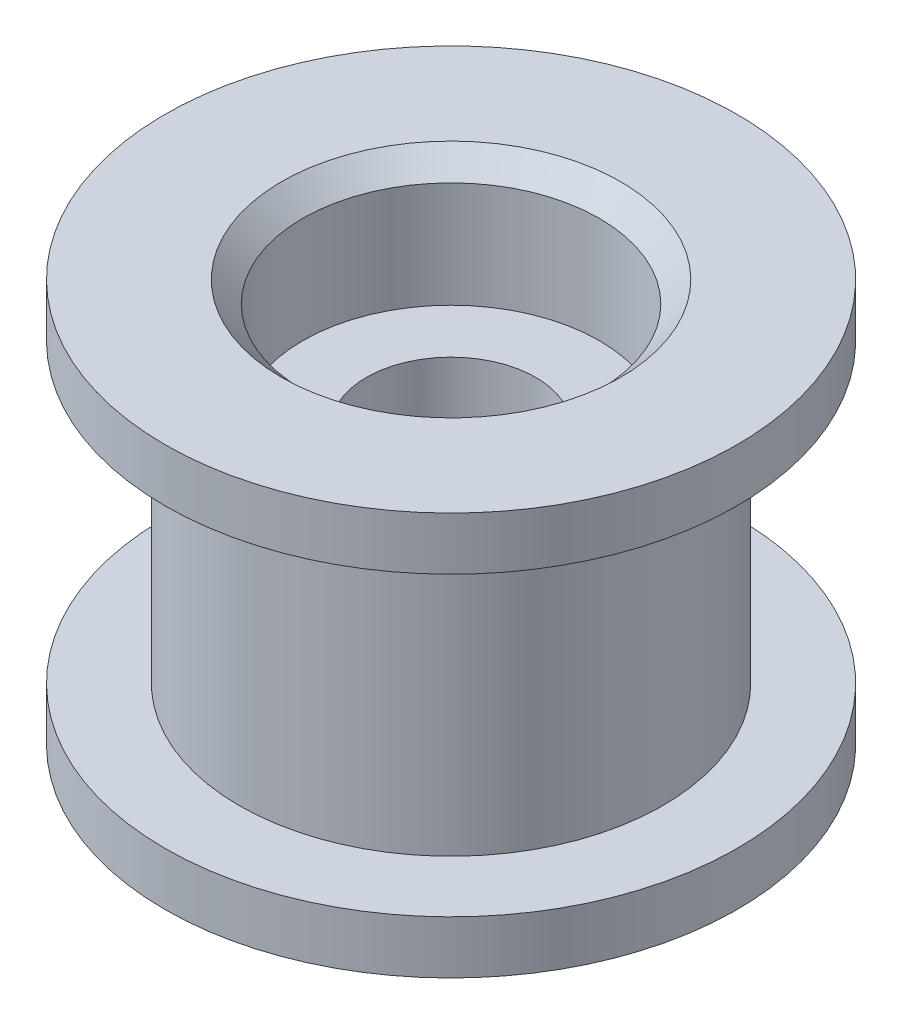
from build123d import *

# Parameters (mm, degrees)
SKETCH2_R           = 5
BOSS_EXTRUDE1_DEPTH = 7
SKETCH3_R           = 6.75
BOSS_EXTRUDE2_DEPTH = 1.25
BOSS_EXTRUDE3_START = -7
SKETCH3_2_R         = 6.75
BOSS_EXTRUDE3_DEPTH = 1.25
SKETCH4_R           = 3.5
CUT_EXTRUDE1_DEPTH  = 3
SKETCH5_R           = 3.5
CUT_EXTRUDE2_DEPTH  = 3
SKETCH6_R           = 2
CUT_EXTRUDE3_DEPTH  = 7.5
CHAMFER1_SIZE       = 0.5


with BuildPart() as part:
    # Sketch2 → Boss-Extrude1 (new body)
    with BuildSketch(Plane(origin=(0, 0, 0), x_dir=(1, 0, 0), z_dir=(0, 1, 0))):
        Circle(SKETCH2_R)
    extrude(amount=BOSS_EXTRUDE1_DEPTH)

    # Sketch3 → Boss-Extrude2 (add)
    with BuildSketch(Plane(origin=(0, 7, 0), x_dir=(1, 0, 0), z_dir=(0, 1, 0))):
        Circle(SKETCH3_R)
    extrude(amount=BOSS_EXTRUDE2_DEPTH)

    # Sketch3_2 → Boss-Extrude3 (add)
    with BuildSketch(Plane(origin=(0, 7, 0), x_dir=(1, 0, 0), z_dir=(0, 1, 0)).offset(BOSS_EXTRUDE3_START)):
        Circle(SKETCH3_2_R)
    extrude(amount=-BOSS_EXTRUDE3_DEPTH)

    # Sketch4 → Cut-Extrude1 (cut)
    with BuildSketch(Plane.XZ.offset(1.25)):
        Circle(SKETCH4_R)
    extrude(amount=-CUT_EXTRUDE1_DEPTH, mode=Mode.SUBTRACT)

    # Sketch5 → Cut-Extrude2 (cut)
    with BuildSketch(Plane(origin=(0, 8.25, 0), x_dir=(1, 0, 0), z_dir=(0, 1, 0))):
        Circle(SKETCH5_R)
    extrude(amount=-CUT_EXTRUDE2_DEPTH, mode=Mode.SUBTRACT)

    # Sketch6 → Cut-Extrude3 (cut, through all)
    with BuildSketch(Plane(origin=(0, 5.25, 0), x_dir=(1, 0, 0), z_dir=(0, 1, 0))):
        Circle(SKETCH6_R)
    extrude(amount=-CUT_EXTRUDE3_DEPTH, mode=Mode.SUBTRACT)

    # Chamfer1
    chamfer1_edges = [part.edges().sort_by_distance(p)[0] for p in [
        (-3.5, -1.25, 0),
        (-3.5, 8.25, 0),
    ]]
    chamfer(chamfer1_edges, length=CHAMFER1_SIZE)


solid = part.part
